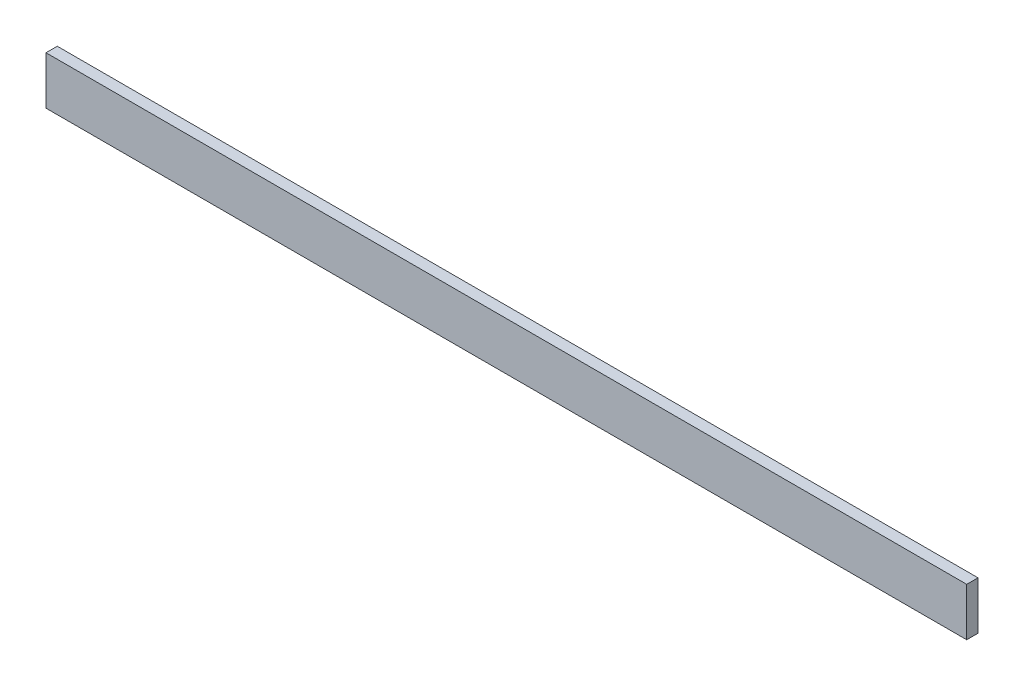
from build123d import *

# Parameters (mm, degrees)
SKETCH1_W           = 973.836
SKETCH1_H           = 50.8
BOSS_EXTRUDE1_DEPTH = 11.938


with BuildPart() as part:
    # Sketch1 → Boss-Extrude1 (new body)
    with BuildSketch(Plane.XY):
        with Locations((486.918, 25.4)):
            Rectangle(SKETCH1_W, SKETCH1_H)
    extrude(amount=BOSS_EXTRUDE1_DEPTH)


solid = part.part
